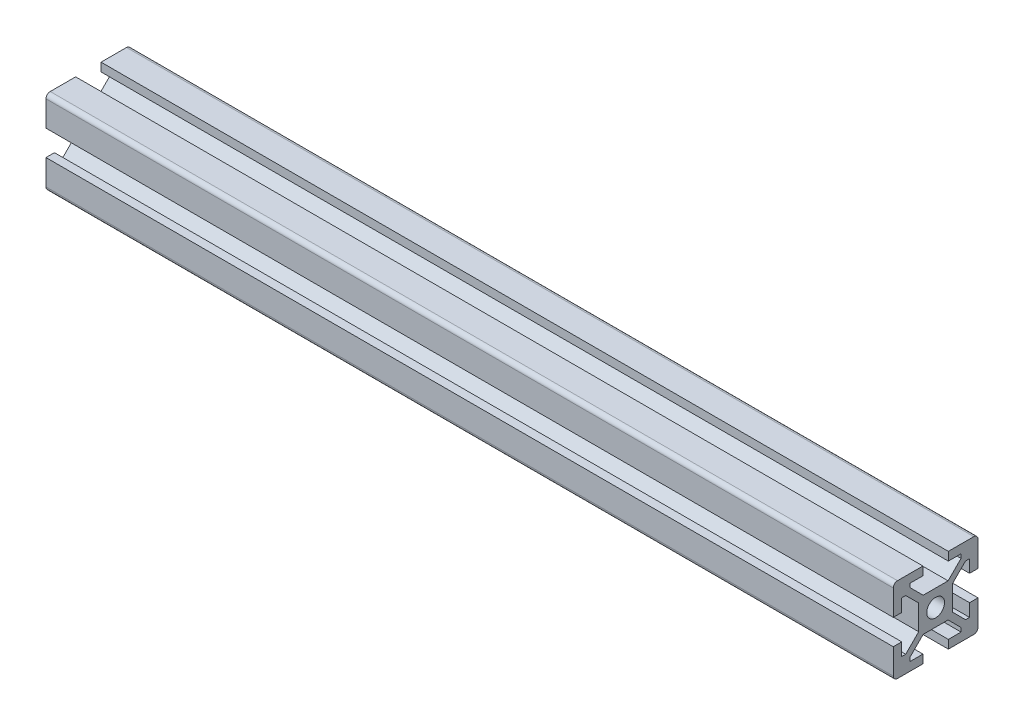
from build123d import *

# Parameters (mm, degrees)
SKETCH1_R           = 2.1
BOSS_EXTRUDE1_DEPTH = 200


with BuildPart() as part:
    # Sketch1 → Boss-Extrude1 (new body)
    with BuildSketch(Plane(origin=(0, 0, 0), x_dir=(0, 0, -1), z_dir=(1, 0, 0))):
        with BuildLine():
            Line((-10, 9), (-10, 3))
            Line((-10, 3), (-8, 3))
            Line((-8, 3), (-8, 6))
            Line((-8, 6), (-7.060660172, 6))
            Line((-7.060660172, 6), (-4, 2.939339828))
            Line((-4, 2.939339828), (-4, -2.939339828))
            Line((-4, -2.939339828), (-7.060660172, -6))
            Line((-7.060660172, -6), (-8, -6))
            Line((-8, -6), (-8, -3))
            Line((-8, -3), (-10, -3))
            Line((-10, -3), (-10, -9))
            ThreePointArc((-10, -9), (-9.707106781, -9.707106781), (-9, -10))
            Line((-9, -10), (-3, -10))
            Line((-3, -10), (-3, -8))
            Line((-3, -8), (-6, -8))
            Line((-6, -8), (-6, -7.060660172))
            Line((-6, -7.060660172), (-2.939339828, -4))
            Line((-2.939339828, -4), (2.939339828, -4))
            Line((2.939339828, -4), (6, -7.060660172))
            Line((6, -7.060660172), (6, -8))
            Line((6, -8), (3, -8))
            Line((3, -8), (3, -10))
            Line((3, -10), (9, -10))
            ThreePointArc((9, -10), (9.707106781, -9.707106781), (10, -9))
            Line((10, -9), (10, -3))
            Line((10, -3), (8, -3))
            Line((8, -3), (8, -6))
            Line((8, -6), (7.060660172, -6))
            Line((7.060660172, -6), (4, -2.939339828))
            Line((4, -2.939339828), (4, 2.939339828))
            Line((4, 2.939339828), (7.060660172, 6))
            Line((7.060660172, 6), (8, 6))
            Line((8, 6), (8, 3))
            Line((8, 3), (10, 3))
            Line((10, 3), (10, 9))
            ThreePointArc((10, 9), (9.707106781, 9.707106781), (9, 10))
            Line((9, 10), (3, 10))
            Line((3, 10), (3, 8))
            Line((3, 8), (6, 8))
            Line((6, 8), (6, 7.060660172))
            Line((6, 7.060660172), (2.939339828, 4))
            Line((2.939339828, 4), (-2.939339828, 4))
            Line((-2.939339828, 4), (-6, 7.060660172))
            Line((-6, 7.060660172), (-6, 8))
            Line((-6, 8), (-3, 8))
            Line((-3, 8), (-3, 10))
            Line((-3, 10), (-9, 10))
            ThreePointArc((-9, 10), (-9.707106781, 9.707106781), (-10, 9))
        make_face()
        Circle(SKETCH1_R, mode=Mode.SUBTRACT)
    extrude(amount=BOSS_EXTRUDE1_DEPTH)


solid = part.part
